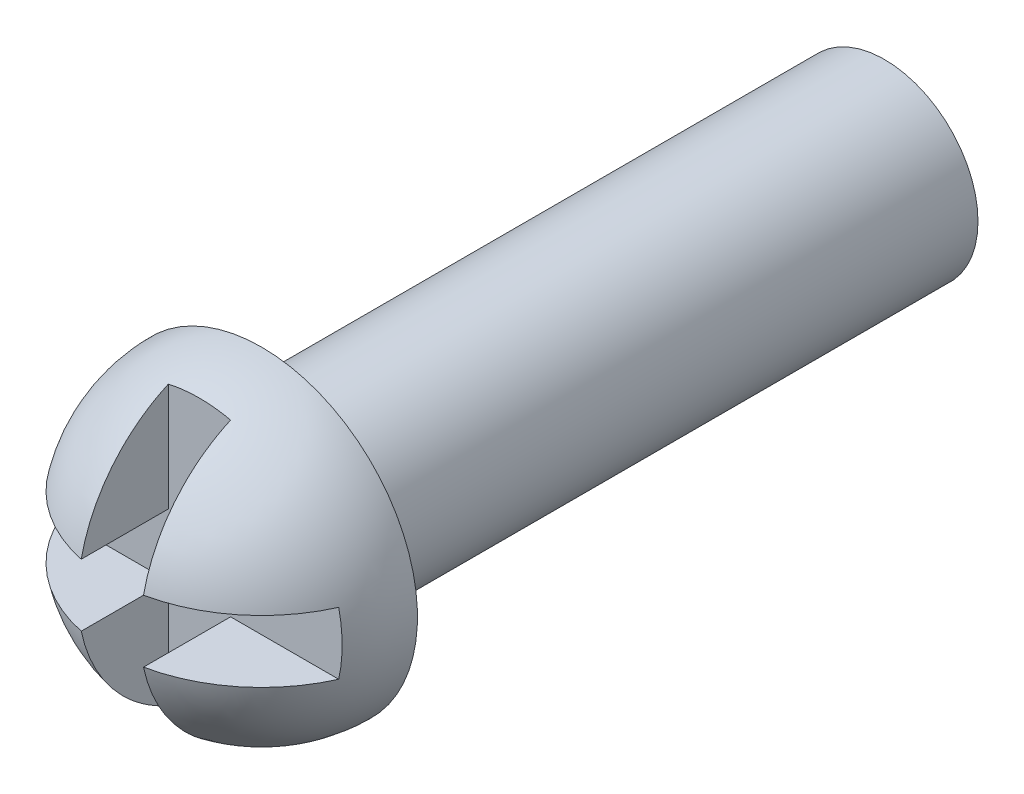
from build123d import *

# Parameters (mm, degrees)
SKETCH1_R           = 1.5
BOSS_EXTRUDE1_DEPTH = 10
REVOLVE1_ANGLE      = 180
CUT_EXTRUDE1_DEPTH  = 2


with BuildPart() as part:
    # Sketch1 → Boss-Extrude1 (new body)
    with BuildSketch(Plane.XY):
        Circle(SKETCH1_R)
    extrude(amount=BOSS_EXTRUDE1_DEPTH)

    # Sketch2 → Revolve1 (revolve)
    with BuildSketch(Plane.XY.offset(10)):
        with BuildLine():
            Line((0, 2.5), (0, -2.5))
            ThreePointArc((0, -2.5), (2.5, 0), (0, 2.5))
        make_face()
    revolve(axis=Axis((0, 2.5, 10), (0, -1, 0)), revolution_arc=REVOLVE1_ANGLE)

    # Sketch3 → Cut-Extrude1 (cut)
    with BuildSketch(Plane.XY.offset(13)):
        Polygon((0.5, 0.5), (3, 0.5), (3, -0.5), (0.5, -0.5), (0.5, -3.070620821), (-0.5, -3.070620821), (-0.5, -0.5), (-3, -0.5), (-3, 0.5), (-0.5, 0.5), (-0.5, 2.929379179), (0.5, 2.929379179), align=None)
    extrude(amount=-CUT_EXTRUDE1_DEPTH, mode=Mode.SUBTRACT)


solid = part.part
